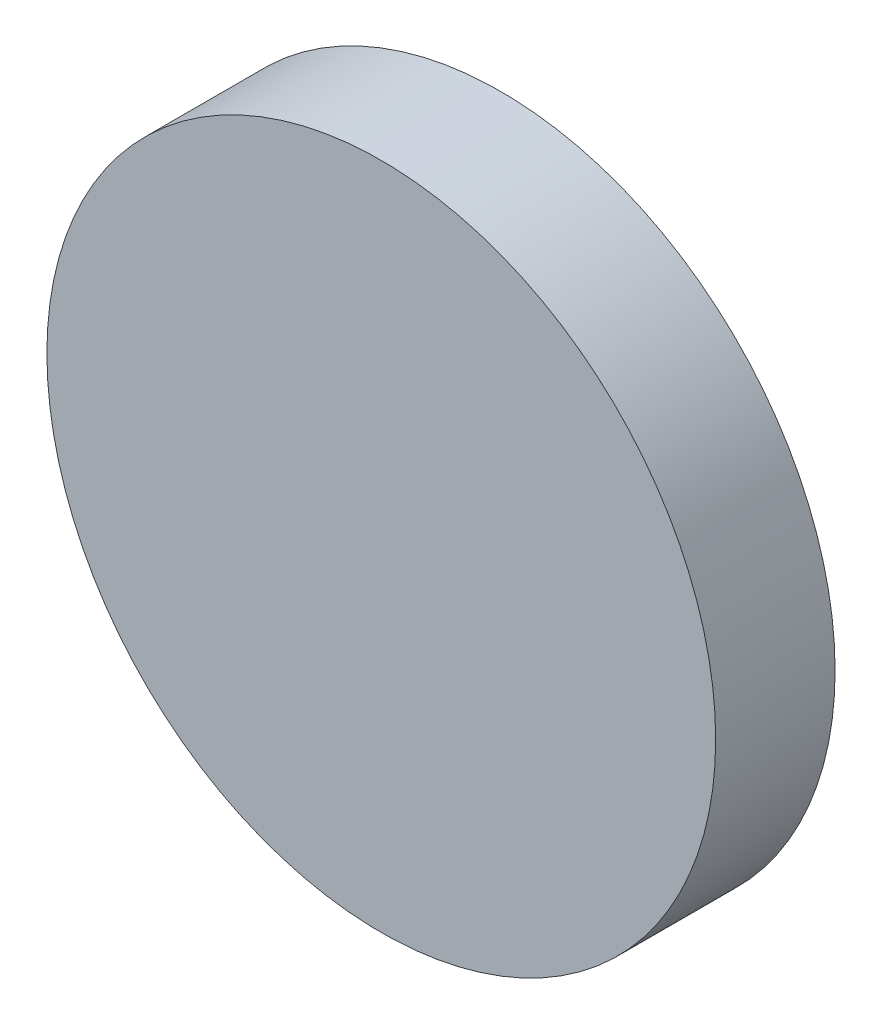
from build123d import *

# Parameters (mm, degrees)
SKETCH2_W          = 2.5
SKETCH2_H          = 1.2
SKETCH2_W_2        = 1.2
SKETCH2_H_2        = 2.5
CUT_EXTRUDE1_DEPTH = 4


with BuildPart() as part:
    # Sketch1 → Revolve1 (revolve)
    with BuildSketch(Plane(origin=(0, 0, 0), x_dir=(1, 0, 0), z_dir=(0, 1, 0))):
        with BuildLine():
            ThreePointArc((10, 48.210245834), (5.423494003, 45.101396028), (0, 44.008204805))
            Line((0, 44.008204805), (0, 43.710245834))
            Line((0, 43.710245834), (14, 43.710245834))
            Line((14, 43.710245834), (14, 48.710245834))
            Line((14, 48.710245834), (12, 48.710245834))
            Line((12, 48.710245834), (12, 48.210245834))
            Line((12, 48.210245834), (10, 48.210245834))
        make_face()
    revolve(axis=Axis((0, 0, -48.710245834), (0, 0, 1)))

    # Sketch2 → Cut-Extrude1 (cut)
    with BuildSketch(Plane(origin=(0, 0, -48.710245834), x_dir=(-1, 0, 0), z_dir=(0, 0, -1))):
        with Locations((0, 13)):
            Rectangle(SKETCH2_W, SKETCH2_H)
        with Locations((-13, 0)):
            Rectangle(SKETCH2_W_2, SKETCH2_H_2)
        with Locations((13, 0)):
            Rectangle(SKETCH2_W_2, SKETCH2_H_2)
        with Locations((0, -13)):
            Rectangle(SKETCH2_W, SKETCH2_H)
    extrude(amount=-CUT_EXTRUDE1_DEPTH, mode=Mode.SUBTRACT)


solid = part.part
